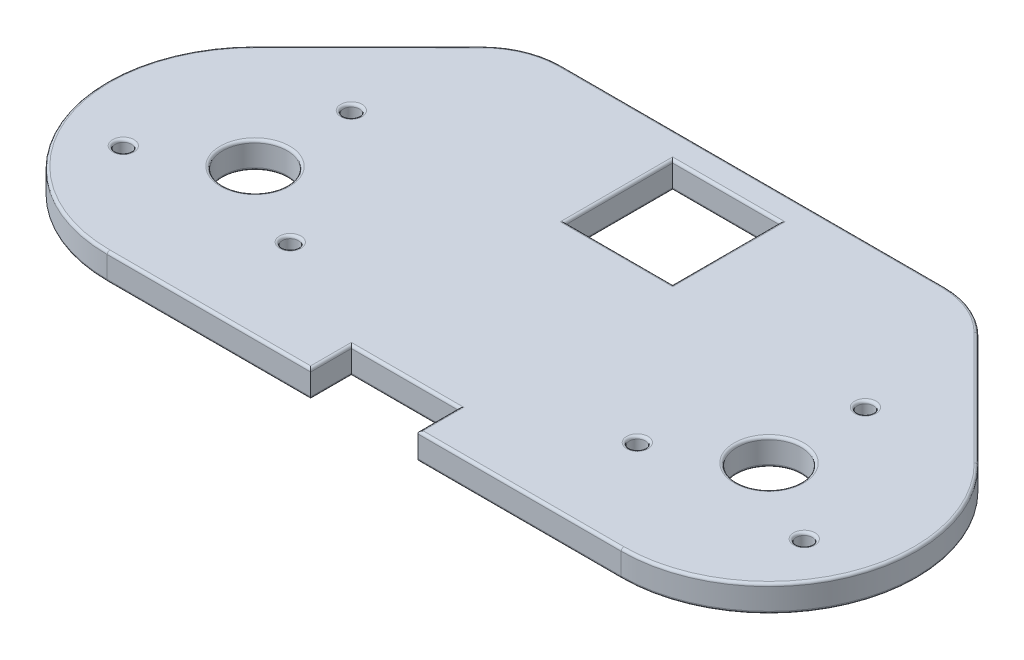
from build123d import *

# Parameters (mm, degrees)
SKETCH_1_W          = 20
SKETCH_1_H          = 20
EXTRUDE_1_DEPTH     = 5
SKETCH_2_R          = 6
CUT_EXTRUDE_1_DEPTH = 6
SKETCH_3_W          = 20
SKETCH_3_H          = 20
CUT_EXTRUDE_2_DEPTH = 6
SKETCH_4_R          = 1.5
CUT_EXTRUDE_3_DEPTH = 6
FILLET_1_R          = 0.5


with BuildPart() as part:
    # 草图1 → 凸台-拉伸1 (new body)
    with BuildSketch(Plane(origin=(0, 0, 0), x_dir=(1, 0, 0), z_dir=(0, 1, 0))):
        with BuildLine():
            Line((-46.190374385, -12.63629204), (49.809625615, -12.63629204))
            ThreePointArc((49.809625615, -12.63629204), (75.312044309, 4.409721), (69.313407814, 34.492212253))
            Line((69.313407814, 34.492212253), (48.201868421, 55.57702551))
            ThreePointArc((48.201868421, 55.57702551), (43.337849269, 58.82371812), (37.601986791, 59.96370796))
            Line((37.601986791, 59.96370796), (1.809625615, 59.96370796))
            Line((1.809625615, 59.96370796), (-33.982735561, 59.96370796))
            ThreePointArc((-33.982735561, 59.96370796), (-39.718598039, 58.82371812), (-44.582617191, 55.57702551))
            Line((-44.582617191, 55.57702551), (-65.694156584, 34.492212253))
            ThreePointArc((-65.694156584, 34.492212253), (-71.692793079, 4.409721), (-46.190374385, -12.63629204))
        make_face()
        with Locations((1.809625615, 44.96370796)):
            Rectangle(SKETCH_1_W, SKETCH_1_H, mode=Mode.SUBTRACT)
    extrude(amount=EXTRUDE_1_DEPTH)

    # 草图2 → 切除-拉伸1 (cut, through all)
    with BuildSketch(Plane(origin=(0, 5, 0), x_dir=(1, 0, 0), z_dir=(0, 1, 0))):
        with Locations((-46.190374385, 14.96370796)):
            Circle(SKETCH_2_R)
        with Locations((49.809625615, 14.96370796)):
            Circle(SKETCH_2_R)
    extrude(amount=-CUT_EXTRUDE_1_DEPTH, mode=Mode.SUBTRACT)

    # 草图3 → 切除-拉伸2 (cut, through all)
    with BuildSketch(Plane(origin=(0, 5, 0), x_dir=(1, 0, 0), z_dir=(0, 1, 0))):
        with Locations((1.809625615, -15.03629204)):
            Rectangle(SKETCH_3_W, SKETCH_3_H)
    extrude(amount=-CUT_EXTRUDE_2_DEPTH, mode=Mode.SUBTRACT)

    # 草图4 → 切除-拉伸3 (cut, through all)
    with BuildSketch(Plane(origin=(0, 5, 0), x_dir=(1, 0, 0), z_dir=(0, 1, 0))):
        with Locations((49.809625615, 32.96370796)):
            Circle(SKETCH_4_R)
        with Locations((65.398082883, 5.96370796)):
            Circle(SKETCH_4_R)
        with Locations((34.221168347, 5.96370796)):
            Circle(SKETCH_4_R)
        with Locations((-30.601917117, 5.96370796)):
            Circle(SKETCH_4_R)
        with Locations((-61.778831653, 5.96370796)):
            Circle(SKETCH_4_R)
        with Locations((-46.190374385, 32.96370796)):
            Circle(SKETCH_4_R)
    extrude(amount=-CUT_EXTRUDE_3_DEPTH, mode=Mode.SUBTRACT)

    # 圆角1
    fillet_1_edges = [part.edges().sort_by_distance(p)[0] for p in [
        (1.809625615, 0, -59.96370796),
        (43.337849269, 0, -58.82371812),
        (58.757638117, 0, -45.034618882),
        (75.312044309, 0, -4.409721),
        (-27.190374385, 0, 12.63629204),
        (-71.692793079, 0, -4.409721),
        (75.312044309, 5, -4.409721),
        (58.757638117, 5, -45.034618882),
        (43.337849269, 5, -58.82371812),
        (1.809625615, 5, -59.96370796),
        (11.809625615, 0, -44.96370796),
        (1.809625615, 0, -54.96370796),
        (-8.190374385, 0, -44.96370796),
        (1.809625615, 0, -34.96370796),
        (11.809625615, 5, -44.96370796),
        (1.809625615, 5, -54.96370796),
        (-8.190374385, 5, -44.96370796),
        (1.809625615, 5, -34.96370796),
        (-39.718598039, 5, -58.82371812),
        (-55.138386887, 5, -45.034618882),
        (-52.190374385, 0, -14.96370796),
        (-52.190374385, 5, -14.96370796),
        (43.809625615, 0, -14.96370796),
        (43.809625615, 5, -14.96370796),
        (-71.692793079, 5, -4.409721),
        (30.809625615, 0, 12.63629204),
        (30.809625615, 5, 12.63629204),
        (11.809625615, 0, 8.83629204),
        (-8.190374385, 0, 8.83629204),
        (11.809625615, 5, 8.83629204),
        (1.809625615, 5, 5.03629204),
        (-8.190374385, 5, 8.83629204),
        (1.809625615, 0, 5.03629204),
        (-47.690374385, 0, -32.96370796),
        (-47.690374385, 5, -32.96370796),
        (-63.278831653, 0, -5.96370796),
        (-63.278831653, 5, -5.96370796),
        (-32.101917117, 0, -5.96370796),
        (-32.101917117, 5, -5.96370796),
        (-27.190374385, 5, 12.63629204),
        (32.721168347, 0, -5.96370796),
        (32.721168347, 5, -5.96370796),
        (63.898082883, 0, -5.96370796),
        (63.898082883, 5, -5.96370796),
        (48.309625615, 0, -32.96370796),
        (48.309625615, 5, -32.96370796),
        (-55.138386887, 0, -45.034618882),
        (-39.718598039, 0, -58.82371812),
    ]]
    fillet(fillet_1_edges, radius=FILLET_1_R)


solid = part.part
